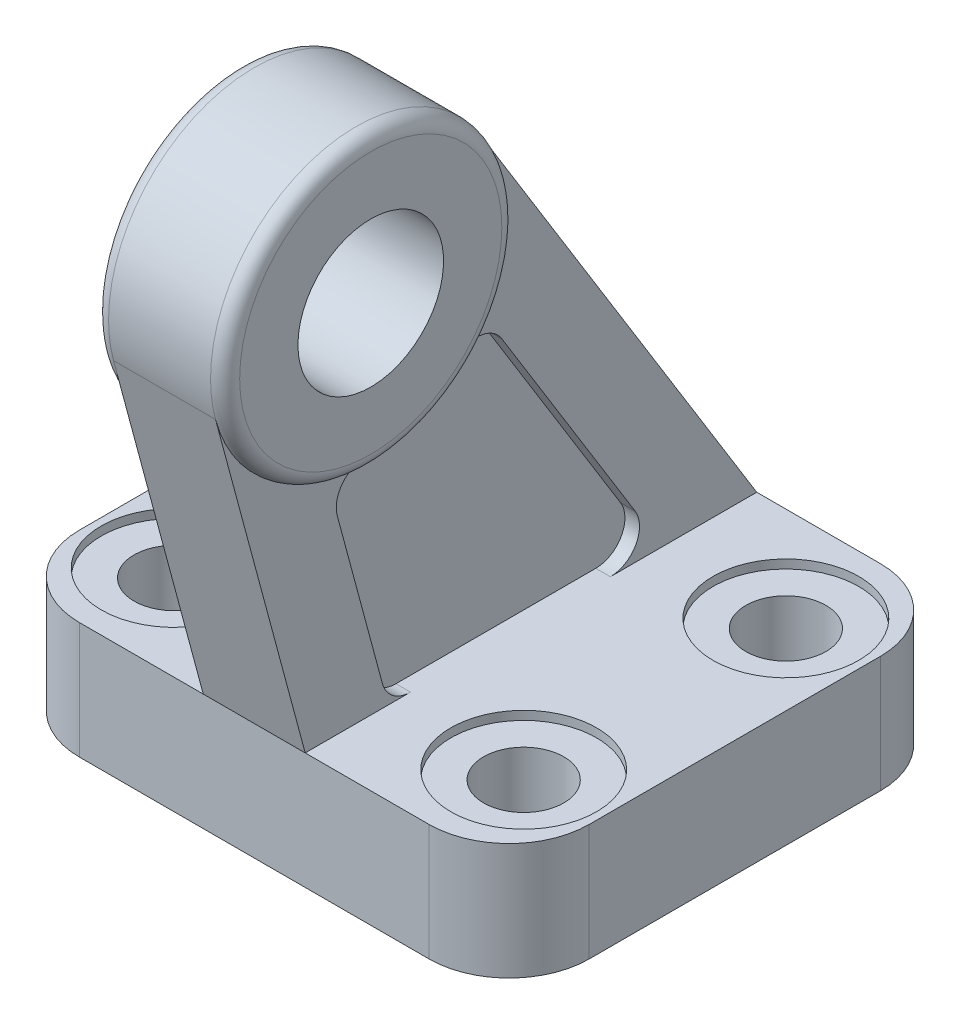
from build123d import *

# Parameters (mm, degrees)
SKETCH1_R                = 2.75
BOSS_EXTRUDE1_DEPTH      = 8
BOSS_EXTRUDE2_DEPTH      = 3.5
BOSS_EXTRUDE2_DEPTH_BACK = 3.5
CUT_EXTRUDE1_DEPTH       = 1
CUT_EXTRUDE2_DEPTH       = 1
CUT_EXTRUDE3_DEPTH       = 4
SKETCH7_R                = 5
CUT_EXTRUDE4_DEPTH       = 0.6
SKETCH8_R                = 5
CUT_EXTRUDE5_DEPTH       = 0.6
SKETCH9_R                = 5
CUT_EXTRUDE6_DEPTH       = 0.6
SKETCH10_R               = 5
CUT_EXTRUDE7_DEPTH       = 0.6


with BuildPart() as part:
    # Sketch1 → Boss-Extrude1 (new body)
    with BuildSketch(Plane(origin=(0, 0, 0), x_dir=(1, 0, 0), z_dir=(0, 1, 0))):
        with BuildLine():
            Line((-12, -15.5), (12, -15.5))
            ThreePointArc((12, -15.5), (15.889087297, -13.889087297), (17.5, -10))
            Line((17.5, -10), (17.5, 10))
            ThreePointArc((17.5, 10), (15.889087297, 13.889087297), (12, 15.5))
            Line((12, 15.5), (-12, 15.5))
            ThreePointArc((-12, 15.5), (-15.889087297, 13.889087297), (-17.5, 10))
            Line((-17.5, 10), (-17.5, -10))
            ThreePointArc((-17.5, -10), (-15.889087297, -13.889087297), (-12, -15.5))
        make_face()
        with Locations((12, 9)):
            Circle(SKETCH1_R, mode=Mode.SUBTRACT)
        with Locations((12, -9)):
            Circle(SKETCH1_R, mode=Mode.SUBTRACT)
        with Locations((-12, 9)):
            Circle(SKETCH1_R, mode=Mode.SUBTRACT)
        with Locations((-12, -9)):
            Circle(SKETCH1_R, mode=Mode.SUBTRACT)
    extrude(amount=BOSS_EXTRUDE1_DEPTH)

    # Sketch2 → Boss-Extrude2 (add, two sides)
    with BuildSketch(Plane(origin=(0, 0, 0), x_dir=(0, 0, -1), z_dir=(1, 0, 0))) as boss_extrude2_sk:
        with BuildLine():
            Line((-21.65714117, 30.903921337), (-15.5, 8))
            Line((-15.5, 8), (15.5, 8))
            Line((15.5, 8), (-3.491565957, 38.754193576))
            ThreePointArc((-3.491565957, 38.754193576), (-8.033064713, 24.320488879), (-21.65714117, 30.903921337))
        make_face()
    extrude(amount=BOSS_EXTRUDE2_DEPTH)
    extrude(boss_extrude2_sk.sketch, amount=-BOSS_EXTRUDE2_DEPTH_BACK)

    # Sketch3 → Cut-Extrude1 (cut)
    with BuildSketch(Plane(origin=(3.5, 0, 0), x_dir=(0, 0, -1), z_dir=(1, 0, 0))):
        with BuildLine():
            Line((-13.298775285, 20.997472945), (-10.202804209, 9.480784267))
            ThreePointArc((-10.202804209, 9.480784267), (-9.48825077, 8.412796254), (-8.271375975, 8))
            Line((-8.271375975, 8), (5.450161602, 8))
            ThreePointArc((5.450161602, 8), (7.196826629, 9.025750912), (7.151848411, 11.050838715))
            Line((7.151848411, 11.050838715), (-2.004518147, 25.878297925))
            ThreePointArc((-2.004518147, 25.878297925), (-3.452381431, 26.811287231), (-5.088504172, 26.272882634))
            ThreePointArc((-5.088504172, 26.272882634), (-8.03306474, 24.320488867), (-11.47278921, 23.513907231))
            ThreePointArc((-11.47278921, 23.513907231), (-12.986087496, 22.691286214), (-13.298775285, 20.997472945))
        make_face()
    extrude(amount=-CUT_EXTRUDE1_DEPTH, mode=Mode.SUBTRACT)

    # Sketch4 → Cut-Extrude2 (cut)
    with BuildSketch(Plane(origin=(-3.5, 0, 0), x_dir=(0, 0, -1), z_dir=(1, 0, 0))):
        with BuildLine():
            Line((-13.298775285, 20.997472945), (-10.202804209, 9.480784267))
            ThreePointArc((-10.202804209, 9.480784267), (-9.48825077, 8.412796254), (-8.271375975, 8))
            Line((-8.271375975, 8), (5.450161602, 8))
            ThreePointArc((5.450161602, 8), (7.196826629, 9.025750912), (7.151848411, 11.050838715))
            Line((7.151848411, 11.050838715), (-2.004518147, 25.878297925))
            ThreePointArc((-2.004518147, 25.878297925), (-3.452381431, 26.811287231), (-5.088504172, 26.272882634))
            ThreePointArc((-5.088504172, 26.272882634), (-8.03306474, 24.320488867), (-11.47278921, 23.513907231))
            ThreePointArc((-11.47278921, 23.513907231), (-12.986087496, 22.691286214), (-13.298775285, 20.997472945))
        make_face()
    extrude(amount=CUT_EXTRUDE2_DEPTH, mode=Mode.SUBTRACT)

    # Sketch5 → Revolve1 (revolve)
    with BuildSketch(Plane.XY.offset(12)):
        with BuildLine():
            Line((-4.5, 42.5), (-4.5, 38.5))
            Line((-4.5, 38.5), (4.5, 38.5))
            Line((4.5, 38.5), (4.5, 42.5))
            ThreePointArc((4.5, 42.5), (4.207106781, 43.207106781), (3.5, 43.5))
            Line((3.5, 43.5), (-3.5, 43.5))
            ThreePointArc((-3.5, 43.5), (-4.207106781, 43.207106781), (-4.5, 42.5))
        make_face()
    revolve(axis=Axis((4.5, 33.5, 12), (-1, 0, 0)))

    # Sketch6 → Cut-Extrude3 (cut)
    with BuildSketch(Plane(origin=(0, 0, 0), x_dir=(1, 0, 0), z_dir=(0, 1, 0))):
        with BuildLine():
            Line((-12, 1.771583853), (-12, -1.771583853))
            ThreePointArc((-12, -1.771583853), (-11.591644792, -2.982644073), (-10.533333143, -3.699161545))
            ThreePointArc((-10.533333143, -3.699161545), (-7.855282825, -5.384572011), (-6.549108126, -8.266666667))
            ThreePointArc((-6.549108126, -8.266666667), (-5.883526804, -9.505545305), (-4.566965626, -10))
            Line((-4.566965626, -10), (4.566965626, -10))
            ThreePointArc((4.566965626, -10), (5.883526804, -9.505545305), (6.549108126, -8.266666667))
            ThreePointArc((6.549108126, -8.266666667), (7.85528289, -5.384571937), (10.533333333, -3.699161492))
            ThreePointArc((10.533333333, -3.699161492), (11.591644852, -2.982643994), (12, -1.771583853))
            Line((12, -1.771583853), (12, 1.771583853))
            ThreePointArc((12, 1.771583853), (11.591644852, 2.982643994), (10.533333333, 3.699161492))
            ThreePointArc((10.533333333, 3.699161492), (7.85528289, 5.384571937), (6.549108126, 8.266666667))
            ThreePointArc((6.549108126, 8.266666667), (5.883526804, 9.505545305), (4.566965626, 10))
            Line((4.566965626, 10), (-4.566965626, 10))
            ThreePointArc((-4.566965626, 10), (-5.883526804, 9.505545305), (-6.549108126, 8.266666667))
            ThreePointArc((-6.549108126, 8.266666667), (-7.855282955, 5.384571863), (-10.533333524, 3.699161439))
            ThreePointArc((-10.533333524, 3.699161439), (-11.591644911, 2.982643916), (-12, 1.771583853))
        make_face()
    extrude(amount=CUT_EXTRUDE3_DEPTH, mode=Mode.SUBTRACT)

    # Sketch7 → Cut-Extrude4 (cut)
    with BuildSketch(Plane(origin=(0, 8, 0), x_dir=(1, 0, 0), z_dir=(0, 1, 0))):
        with Locations((12, 9)):
            Circle(SKETCH7_R)
    extrude(amount=-CUT_EXTRUDE4_DEPTH, mode=Mode.SUBTRACT)

    # Sketch8 → Cut-Extrude5 (cut)
    with BuildSketch(Plane(origin=(0, 8, 0), x_dir=(1, 0, 0), z_dir=(0, 1, 0))):
        with Locations((-12, 9)):
            Circle(SKETCH8_R)
    extrude(amount=-CUT_EXTRUDE5_DEPTH, mode=Mode.SUBTRACT)

    # Sketch9 → Cut-Extrude6 (cut)
    with BuildSketch(Plane(origin=(0, 8, 0), x_dir=(1, 0, 0), z_dir=(0, 1, 0))):
        with Locations((12, -9)):
            Circle(SKETCH9_R)
    extrude(amount=-CUT_EXTRUDE6_DEPTH, mode=Mode.SUBTRACT)

    # Sketch10 → Cut-Extrude7 (cut)
    with BuildSketch(Plane(origin=(0, 8, 0), x_dir=(1, 0, 0), z_dir=(0, 1, 0))):
        with Locations((-12, -9)):
            Circle(SKETCH10_R)
    extrude(amount=-CUT_EXTRUDE7_DEPTH, mode=Mode.SUBTRACT)


solid = part.part
